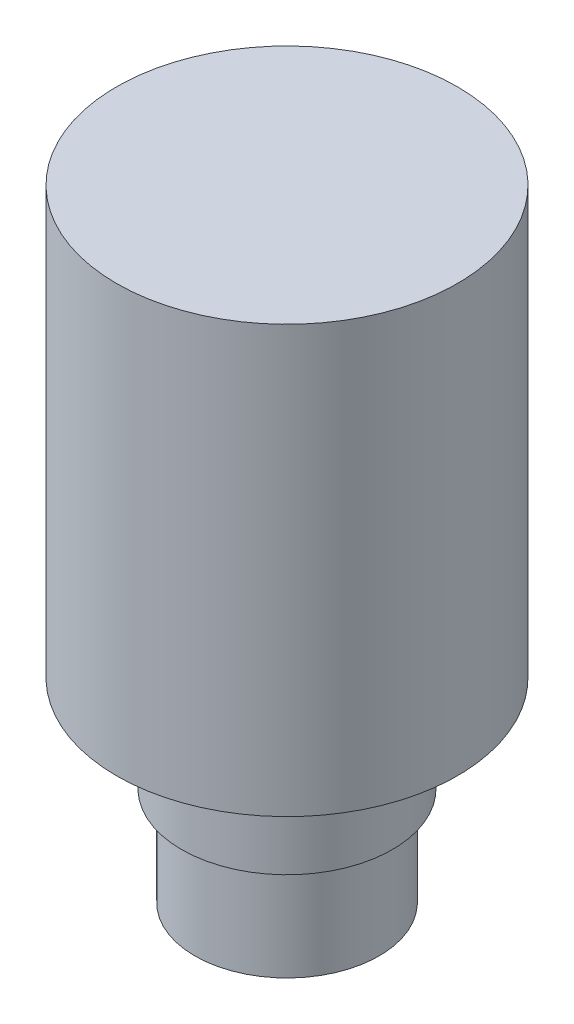
from build123d import *


with BuildPart() as part:
    # Sketch1 → Revolve1 (revolve)
    with BuildSketch(Plane(origin=(0, 0, 0), x_dir=(0, 0, -1), z_dir=(1, 0, 0))):
        Polygon((0, 0), (0, 131.064), (35.941, 131.064), (35.941, 41.148), (19.431, 41.148), (19.431, 34.798), (22.225, 34.798), (22.225, 20.828), (19.431, 20.828), (19.431, 0), align=None)
    revolve(axis=Axis((0, 0, 0), (0, 1, 0)))


solid = part.part
